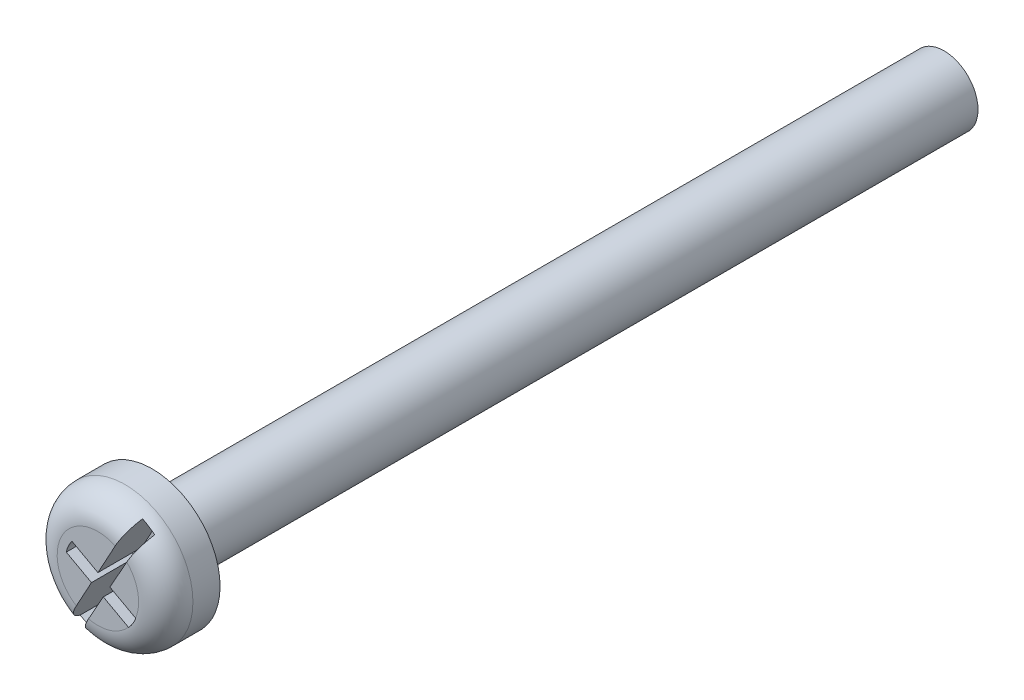
from build123d import *

# Parameters (mm, degrees)
SZKIC1_R                    = 3
DODANIE_WYCI_GNI_CIE2_DEPTH = 2.4
SZKIC2_R                    = 1.5
DODANIE_WYCI_GNI_CIE3_DEPTH = 35
ZAOKR_GLENIE2_R             = 1.2
WYTNIJ_WYCI_GNI_CIE1_DEPTH  = 1.94


with BuildPart() as part:
    # Szkic1 → Dodanie-wyciągnięcie2 (new body)
    with BuildSketch(Plane.XY):
        with Locations((-1.860516246, 2.732142857)):
            Circle(SZKIC1_R)
    extrude(amount=DODANIE_WYCI_GNI_CIE2_DEPTH)

    # Szkic2 → Dodanie-wyciągnięcie3 (add)
    with BuildSketch(Plane(origin=(0, 0, 0), x_dir=(-1, 0, 0), z_dir=(0, 0, -1))):
        with Locations((1.860516246, 2.732142857)):
            Circle(SZKIC2_R)
    extrude(amount=DODANIE_WYCI_GNI_CIE3_DEPTH)

    # Zaokrąglenie2
    zaokr_glenie2_edges = [part.edges().sort_by_distance(p)[0] for p in [
        (-4.860516246, 2.732142857, 2.4),
    ]]
    fillet(zaokr_glenie2_edges, radius=ZAOKR_GLENIE2_R)

    # Szkic3 → Wytnij-wyciągnięcie1 (cut)
    with BuildSketch(Plane.XY.offset(2.4)):
        with BuildLine():
            Line((-1.859548318, 2.959091853), (-0.575649693, 5.316481314))
            ThreePointArc((-0.575649693, 5.316481314), (-0.297886623, 5.158637444), (-0.039271083, 4.97106076))
            Line((-0.039271083, 4.97106076), (-1.329373025, 2.669425378))
            Line((-1.329373025, 2.669425378), (-0.183967515, 2.043621837))
            ThreePointArc((-0.183967515, 2.043621837), (-0.320475658, 1.776553075), (-0.499159616, 1.535654258))
            Line((-0.499159616, 1.535654258), (-1.621312108, 2.148584891))
            Line((-1.621312108, 2.148584891), (-2.819933608, 0.01015725))
            ThreePointArc((-2.819933608, 0.01015725), (-3.083174674, 0.117799023), (-3.33454353, 0.250826496))
            Line((-3.33454353, 0.250826496), (-2.145142944, 2.434706401))
            Line((-2.145142944, 2.434706401), (-3.258687897, 3.042935511))
            ThreePointArc((-3.258687897, 3.042935511), (-3.162842423, 3.328316127), (-3.009463836, 3.587359481))
            Line((-3.009463836, 3.587359481), (-1.859548318, 2.959091853))
        make_face()
    extrude(amount=-WYTNIJ_WYCI_GNI_CIE1_DEPTH, mode=Mode.SUBTRACT)


solid = part.part
